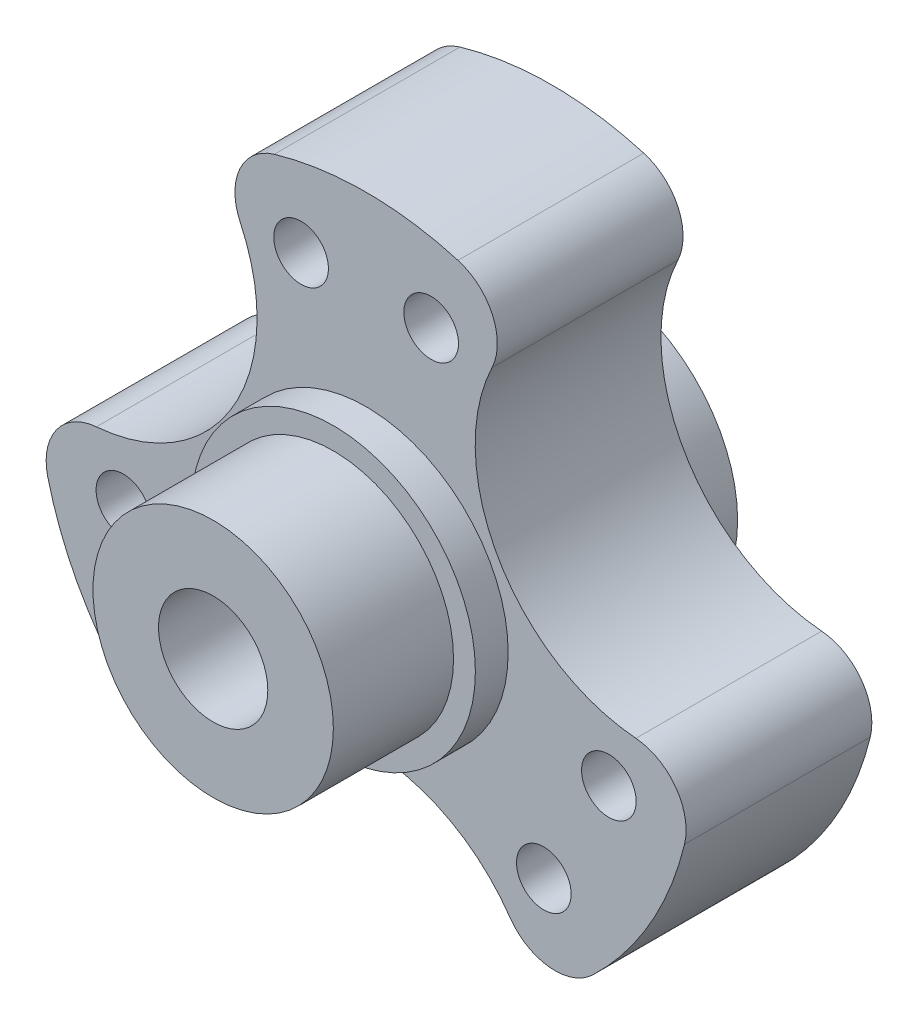
from build123d import *

# Parameters (mm, degrees)
SKETCH_1_R               = 30
SKETCH_1_R_2             = 2.5
EXTRUDE_1_DEPTH          = 17
SKETCH_2_R               = 16
CUT_EXTRUDE_1_DEPTH      = 18
PATTERN_CIRCULAR_1_COUNT = 3
SKETCH_4_R               = 11
EXTRUDE_3_DEPTH          = 14
SKETCH_5_R               = 5
CUT_EXTRUDE_2_DEPTH      = 32
SKETCH_6_W               = 4
SKETCH_6_H               = 2.5
CUT_EXTRUDE_3_DEPTH      = 32
SKETCH_7_R               = 13
EXTRUDE_4_DEPTH          = 4
EXTRUDE_5_DEPTH          = 35
SKETCH_10_R              = 13
SKETCH_10_R_2            = 11
EXTRUDE_8_DEPTH          = 3
FILLET_1_R               = 5


with BuildPart() as part:
    # 草图1 → 凸台-拉伸1 (new body)
    with BuildSketch(Plane.XY):
        Circle(SKETCH_1_R)
        with Locations((-5.952838037, 22.216294005)):
            Circle(SKETCH_1_R_2, mode=Mode.SUBTRACT)
        with Locations((5.952838037, 22.216294005)):
            Circle(SKETCH_1_R_2, mode=Mode.SUBTRACT)
        with Locations((22.216294005, -5.952838037)):
            Circle(SKETCH_1_R_2, mode=Mode.SUBTRACT)
        with Locations((16.263455967, -16.263455967)):
            Circle(SKETCH_1_R_2, mode=Mode.SUBTRACT)
        with Locations((-16.263455967, -16.263455967)):
            Circle(SKETCH_1_R_2, mode=Mode.SUBTRACT)
        with Locations((-22.216294005, -5.952838037)):
            Circle(SKETCH_1_R_2, mode=Mode.SUBTRACT)
    extrude(amount=EXTRUDE_1_DEPTH)

    # 草图2 → 切除-拉伸1 (cut, through all)
    with BuildSketch(Plane.XY.offset(17)):
        with Locations((25.980762114, 15)):
            Circle(SKETCH_2_R)
    cut_extrude_1 = extrude(amount=-CUT_EXTRUDE_1_DEPTH, mode=Mode.SUBTRACT)

    # 阵列(圆周)1: 切除-拉伸1 ×3 about axis
    pattern_circular_1_axis = Axis((0, 0, 0), (0, 0, 1))
    for i in range(1, PATTERN_CIRCULAR_1_COUNT):
        add(cut_extrude_1.rotate(pattern_circular_1_axis, i * 360 / PATTERN_CIRCULAR_1_COUNT), mode=Mode.SUBTRACT)

    # 草图4 → 凸台-拉伸3 (add)
    with BuildSketch(Plane.XY.offset(17)):
        Circle(SKETCH_4_R)
    extrude(amount=EXTRUDE_3_DEPTH)

    # 草图5 → 切除-拉伸2 (cut, through all)
    with BuildSketch(Plane.XY.offset(31)):
        Circle(SKETCH_5_R)
    extrude(amount=-CUT_EXTRUDE_2_DEPTH, mode=Mode.SUBTRACT)

    # 草图6 → 切除-拉伸3 (cut, through all)
    with BuildSketch(Plane.XY.offset(31)):
        with Locations((0, 5)):
            Rectangle(SKETCH_6_W, SKETCH_6_H)
    extrude(amount=-CUT_EXTRUDE_3_DEPTH, mode=Mode.SUBTRACT)

    # 草图7 → 凸台-拉伸4 (add)
    with BuildSketch(Plane(origin=(0, 0, 0), x_dir=(-1, 0, 0), z_dir=(0, 0, -1))):
        Circle(SKETCH_7_R)
        with BuildLine():
            Line((-2, 4.582575695), (-2, 6.25))
            Line((-2, 6.25), (2, 6.25))
            Line((2, 6.25), (2, 4.582575695))
            ThreePointArc((2, 4.582575695), (0, -5), (-2, 4.582575695))
        make_face(mode=Mode.SUBTRACT)
    extrude(amount=EXTRUDE_4_DEPTH)

    # 草图8 → 凸台-拉伸5 (add)
    with BuildSketch(Plane(origin=(0, 0, -4), x_dir=(-1, 0, 0), z_dir=(0, 0, -1))):
        with BuildLine():
            Line((-2, 4.582575695), (-2, 6.25))
            Line((-2, 6.25), (2, 6.25))
            Line((2, 6.25), (2, 4.582575695))
            ThreePointArc((2, 4.582575695), (0, 5), (-2, 4.582575695))
        make_face()
    extrude(amount=-EXTRUDE_5_DEPTH)

    # 草图10 → 凸台-拉伸8 (add)
    with BuildSketch(Plane.XY.offset(17)):
        Circle(SKETCH_10_R)
        Circle(SKETCH_10_R_2, mode=Mode.SUBTRACT)
    extrude(amount=EXTRUDE_8_DEPTH)

    # 圆角1
    fillet_1_edges = [part.edges().sort_by_distance(p)[0] for p in [
        (14.575409833, 26.221316294, 8.5),
        (29.996030948, -0.487982961, 8.5),
        (-29.996030948, -0.487982961, 8.5),
        (-14.575409833, 26.221316294, 8.5),
        (15.420621114, -25.733333333, 8.5),
        (-15.420621114, -25.733333333, 8.5),
    ]]
    fillet(fillet_1_edges, radius=FILLET_1_R)


solid = part.part
